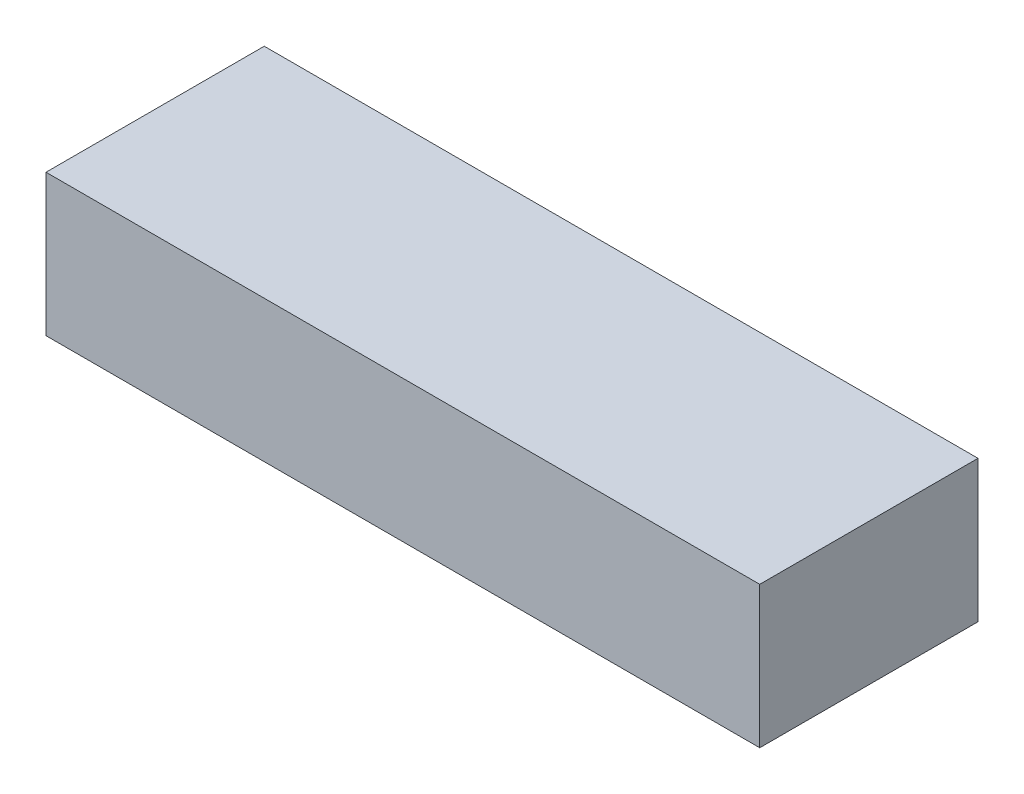
from build123d import *

# Parameters (mm, degrees)
SKETCH1_W           = 1536.7
SKETCH1_H           = 469.9
BOSS_EXTRUDE1_DEPTH = 304.8


with BuildPart() as part:
    # Sketch1 → Boss-Extrude1 (new body)
    with BuildSketch(Plane(origin=(0, 0, 0), x_dir=(1, 0, 0), z_dir=(0, 1, 0))):
        with Locations((768.35, 234.95)):
            Rectangle(SKETCH1_W, SKETCH1_H)
    extrude(amount=-BOSS_EXTRUDE1_DEPTH)


solid = part.part
